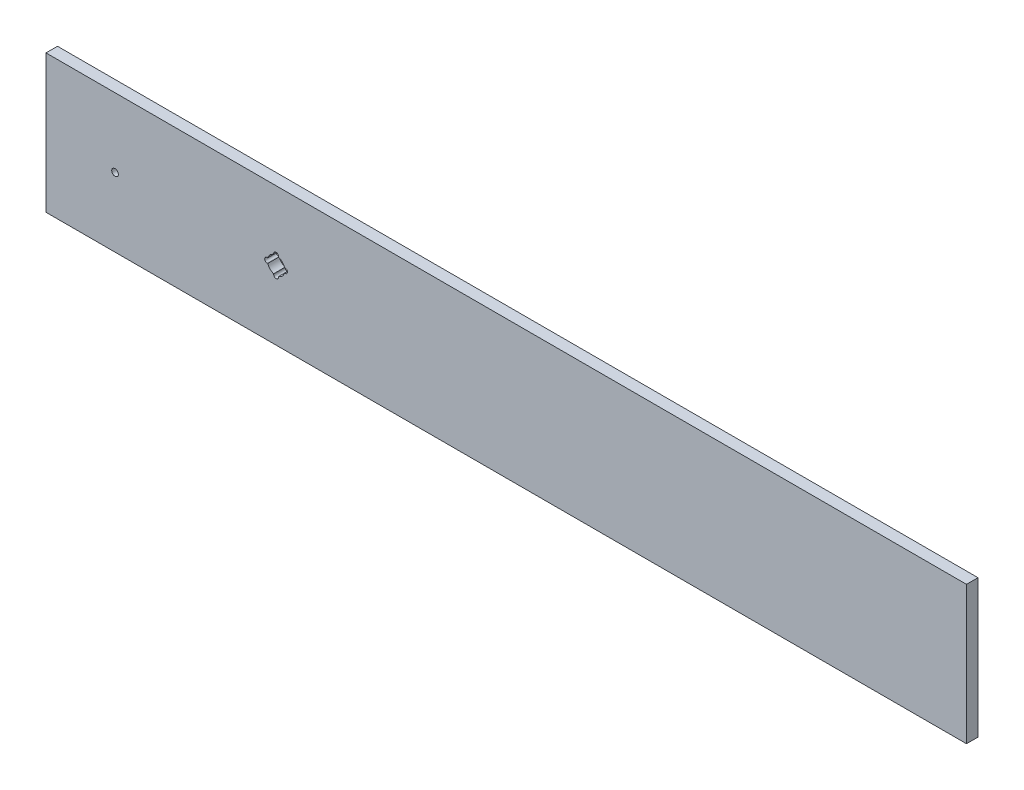
from build123d import *

# Parameters (mm, degrees)
SKETCH1_W           = 508
SKETCH1_H           = 76.2
BOSS_EXTRUDE1_DEPTH = 6.35
CUT_EXTRUDE3_DEPTH  = 7.35
SKETCH3_R           = 1.8415
CUT_EXTRUDE4_DEPTH  = 7.35


with BuildPart() as part:
    # Sketch1 → Boss-Extrude1 (new body)
    with BuildSketch(Plane.XY):
        with Locations((254, 38.1)):
            Rectangle(SKETCH1_W, SKETCH1_H)
    extrude(amount=BOSS_EXTRUDE1_DEPTH)

    # Sketch2 → Cut-Extrude3 (cut, through all)
    with BuildSketch(Plane.XY.offset(6.35)):
        with BuildLine():
            ThreePointArc((128.3462, 43.053), (127, 44.3992), (125.6538, 43.053))
            Line((125.6538, 43.053), (125.6538, 42.707982847))
            ThreePointArc((125.6538, 42.707982847), (123.605463186, 41.494536814), (122.392017153, 39.4462))
            Line((122.392017153, 39.4462), (122.047, 39.4462))
            ThreePointArc((122.047, 39.4462), (120.7008, 38.1), (122.047, 36.7538))
            Line((122.047, 36.7538), (122.392017153, 36.7538))
            ThreePointArc((122.392017153, 36.7538), (123.605463186, 34.705463186), (125.6538, 33.492017153))
            Line((125.6538, 33.492017153), (125.6538, 33.147))
            ThreePointArc((125.6538, 33.147), (127, 31.8008), (128.3462, 33.147))
            Line((128.3462, 33.147), (128.3462, 33.492017153))
            ThreePointArc((128.3462, 33.492017153), (130.394536814, 34.705463186), (131.607982847, 36.7538))
            Line((131.607982847, 36.7538), (131.953, 36.7538))
            ThreePointArc((131.953, 36.7538), (133.2992, 38.1), (131.953, 39.4462))
            Line((131.953, 39.4462), (131.607982847, 39.4462))
            ThreePointArc((131.607982847, 39.4462), (130.394536814, 41.494536814), (128.3462, 42.707982847))
            Line((128.3462, 42.707982847), (128.3462, 43.053))
        make_face()
    extrude(amount=-CUT_EXTRUDE3_DEPTH, mode=Mode.SUBTRACT)

    # Sketch3 → Cut-Extrude4 (cut, through all)
    with BuildSketch(Plane.XY.offset(6.35)):
        with Locations((38.1, 38.1)):
            Circle(SKETCH3_R)
    extrude(amount=-CUT_EXTRUDE4_DEPTH, mode=Mode.SUBTRACT)


solid = part.part
